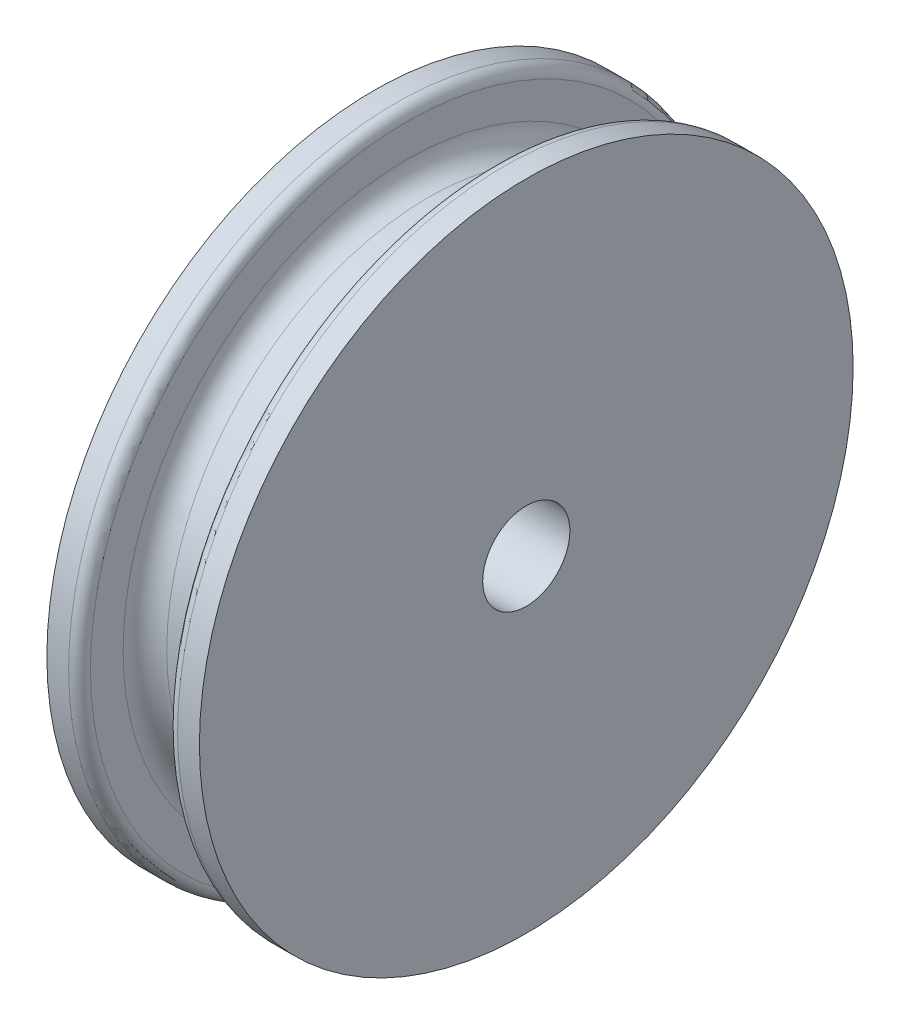
from build123d import *

# Parameters (mm, degrees)
FILLET1_R = 0.25


with BuildPart() as part:
    # Sketch1 → Revolve1 (revolve)
    with BuildSketch(Plane.XY):
        with BuildLine():
            Line((-1.75, 1), (1.75, 1))
            Line((1.75, 1), (1.75, 7.5))
            Line((1.75, 7.5), (1, 7.5))
            Line((1, 7.5), (1, 6.5))
            ThreePointArc((1, 6.5), (0.853553391, 6.146446609), (0.5, 6))
            Line((0.5, 6), (-0.5, 6))
            ThreePointArc((-0.5, 6), (-0.853553391, 6.146446609), (-1, 6.5))
            Line((-1, 6.5), (-1, 7.5))
            Line((-1, 7.5), (-1.75, 7.5))
            Line((-1.75, 7.5), (-1.75, 1))
        make_face()
    revolve(axis=Axis((0, 0, 0), (1, 0, 0)))

    # Fillet1
    fillet1_edges = [part.edges().sort_by_distance(p)[0] for p in [
        (1, -7.5, 0),
        (-1, -7.5, 0),
    ]]
    fillet(fillet1_edges, radius=FILLET1_R)


solid = part.part
